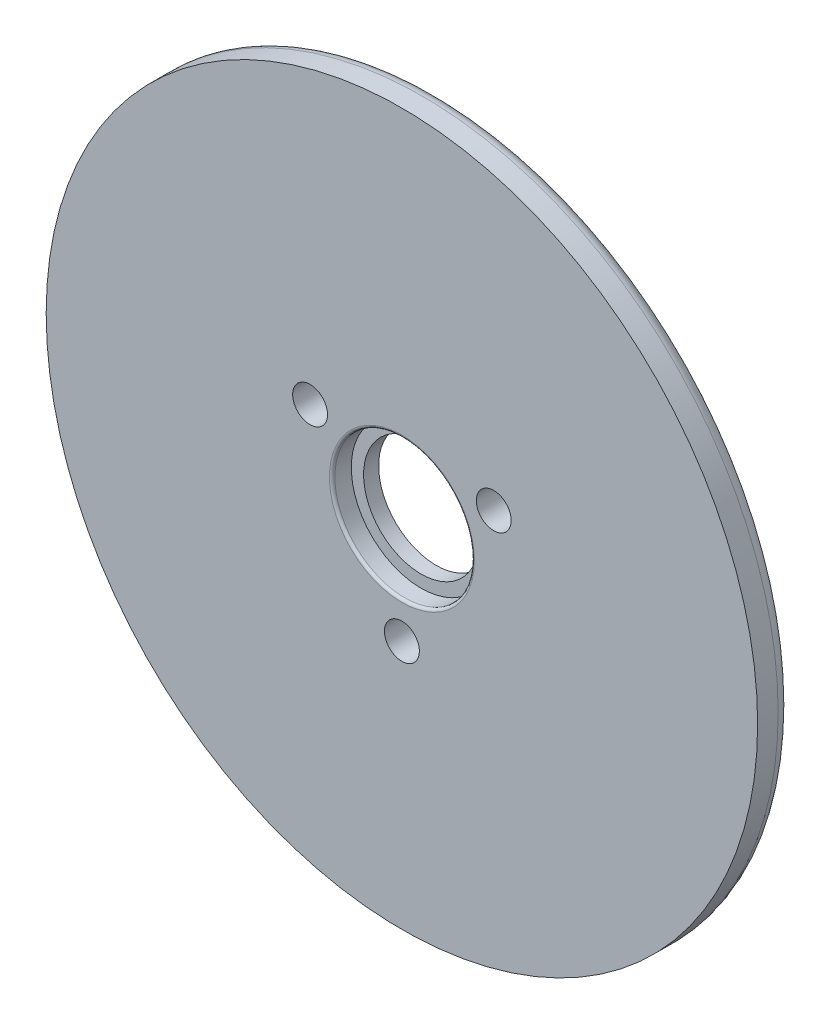
from build123d import *

# Parameters (mm, degrees)
SKETCH1_R           = 26
SKETCH1_R_2         = 4.2
SKETCH1_R_3         = 1.275
BOSS_EXTRUDE1_DEPTH = 2.5
SKETCH2_R           = 5.1
CUT_EXTRUDE1_DEPTH  = 1.4
FILLET1_R           = 0.2
FILLET2_R           = 1


with BuildPart() as part:
    # Sketch1 → Boss-Extrude1 (new body)
    with BuildSketch(Plane.XY):
        Circle(SKETCH1_R)
        Circle(SKETCH1_R_2, mode=Mode.SUBTRACT)
        with Locations((0, -7.75)):
            Circle(SKETCH1_R_3, mode=Mode.SUBTRACT)
        with Locations((-6.711696879, 3.875)):
            Circle(SKETCH1_R_3, mode=Mode.SUBTRACT)
        with Locations((6.711696879, 3.875)):
            Circle(SKETCH1_R_3, mode=Mode.SUBTRACT)
    extrude(amount=BOSS_EXTRUDE1_DEPTH)

    # Sketch2 → Cut-Extrude1 (cut)
    with BuildSketch(Plane.XY.offset(2.5)):
        Circle(SKETCH2_R)
    extrude(amount=-CUT_EXTRUDE1_DEPTH, mode=Mode.SUBTRACT)

    # Fillet1
    fillet1_edges = [part.edges().sort_by_distance(p)[0] for p in [
        (-5.1, 0, 2.5),
    ]]
    fillet(fillet1_edges, radius=FILLET1_R)

    # Fillet2
    fillet2_edges = [part.edges().sort_by_distance(p)[0] for p in [
        (-26, 0, 0),
    ]]
    fillet(fillet2_edges, radius=FILLET2_R)


solid = part.part
